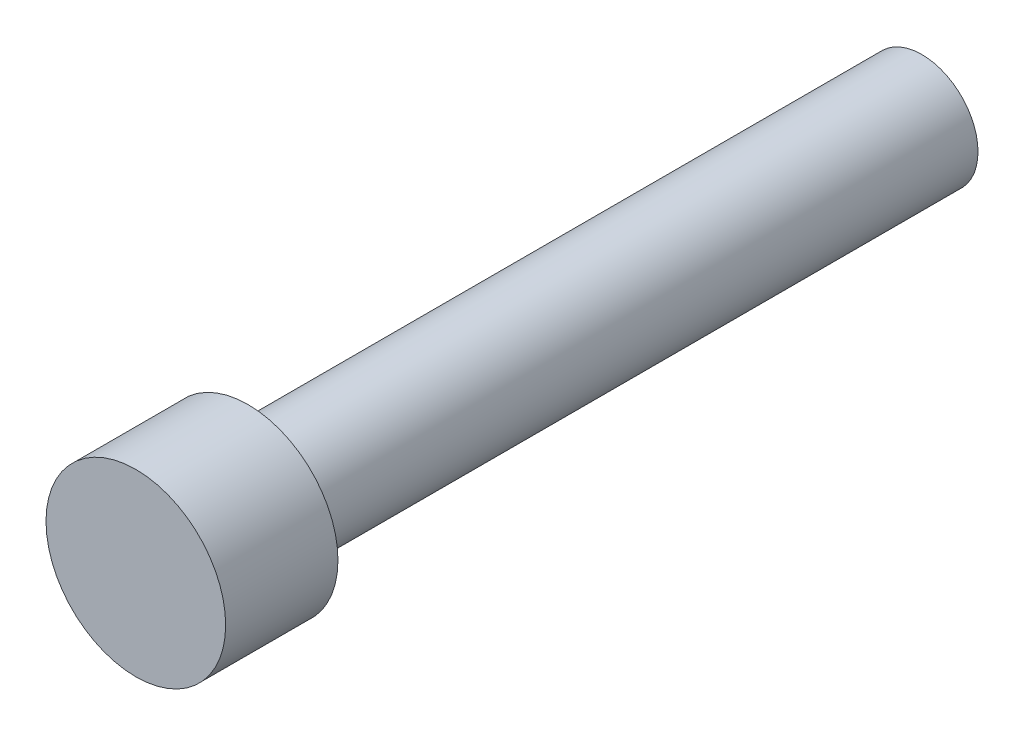
from build123d import *

# Parameters (mm, degrees)
SKETCH1_R           = 2.5
BOSS_EXTRUDE1_DEPTH = 30
SKETCH2_R           = 4
BOSS_EXTRUDE2_DEPTH = 5


with BuildPart() as part:
    # Sketch1 → Boss-Extrude1 (new body)
    with BuildSketch(Plane.XY):
        Circle(SKETCH1_R)
    extrude(amount=BOSS_EXTRUDE1_DEPTH)

    # Sketch2 → Boss-Extrude2 (add)
    with BuildSketch(Plane.XY.offset(30)):
        Circle(SKETCH2_R)
    extrude(amount=BOSS_EXTRUDE2_DEPTH)


solid = part.part
